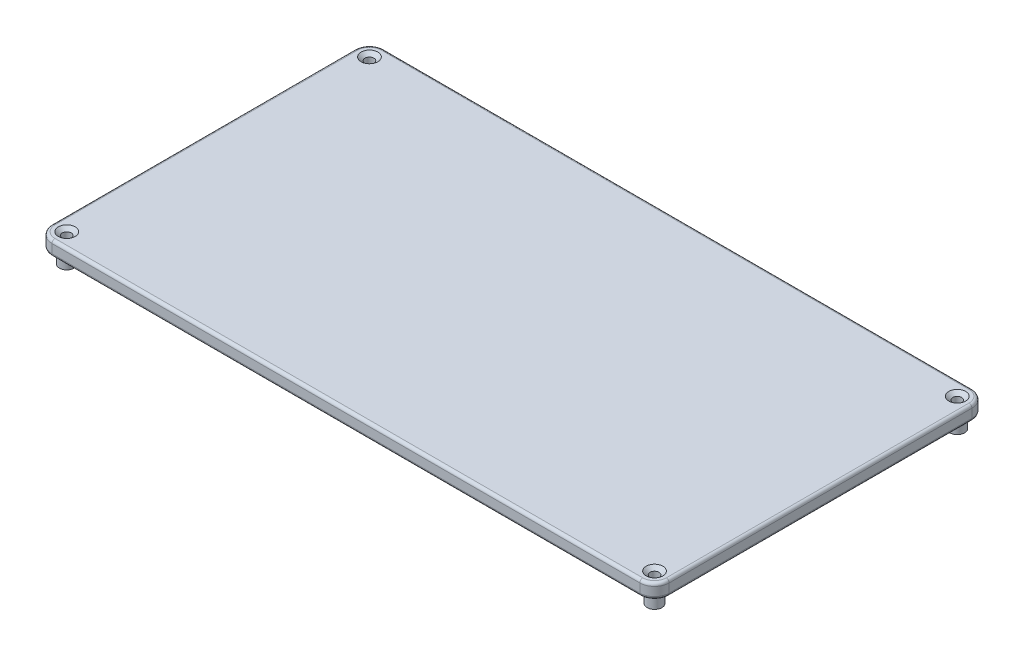
from build123d import *

# Parameters (mm, degrees)
SKETCH1_W                                         = 210
SKETCH1_H                                         = 113
BOSS_EXTRUDE1_DEPTH                               = 5
FILLET1_R                                         = 5
FILLET2_R                                         = 1
CSK_FOR_4_FLAT_HEAD_MACHINE_SCREW_100_D           = 2.9464
CSK_FOR_4_FLAT_HEAD_MACHINE_SCREW_100_CSINK_D     = 5.715
CSK_FOR_4_FLAT_HEAD_MACHINE_SCREW_100_CSINK_ANGLE = 100
SKETCH8_R                                         = 2.4732
BOSS_EXTRUDE2_DEPTH                               = 4.525
SKETCH10_R                                        = 1.525
CUT_EXTRUDE1_DEPTH                                = 1
CUT_EXTRUDE1_DEPTH_BACK                           = 10.525
SKETCH11_R                                        = 2.525
BOSS_EXTRUDE3_DEPTH                               = 4.525
SKETCH14_R                                        = 1.525
CUT_EXTRUDE2_DEPTH                                = 10.5250001
SKETCH15_R                                        = 2.525
BOSS_EXTRUDE6_DEPTH                               = 4.525
SKETCH16_R                                        = 1.525
CUT_EXTRUDE3_DEPTH                                = 10.5250001
SKETCH17_R                                        = 2.525
BOSS_EXTRUDE7_DEPTH                               = 4.525
SKETCH18_R                                        = 1.525
CUT_EXTRUDE4_DEPTH                                = 10.5250001


with BuildPart() as part:
    # Sketch1 → Boss-Extrude1 (new body)
    with BuildSketch(Plane(origin=(0, 0, 0), x_dir=(1, 0, 0), z_dir=(0, 1, 0))):
        Rectangle(SKETCH1_W, SKETCH1_H)
    extrude(amount=BOSS_EXTRUDE1_DEPTH)

    # Fillet1
    fillet1_edges = [part.edges().sort_by_distance(p)[0] for p in [
        (105, 2.5, 56.5),
        (-105, 2.5, 56.5),
        (-105, 2.5, -56.5),
        (105, 2.5, -56.5),
    ]]
    fillet(fillet1_edges, radius=FILLET1_R)

    # Fillet2
    fillet2_edges = [part.edges().sort_by_distance(p)[0] for p in [
        (-105, 0, 0),
        (-105, 5, 0),
        (105, 0, 0),
        (0, 0, 56.5),
        (0, 0, -56.5),
        (103.535533906, 0, -55.035533906),
        (103.535533906, 0, 55.035533906),
        (-103.535533906, 0, 55.035533906),
        (-103.535533906, 0, -55.035533906),
        (0, 5, -56.5),
        (105, 5, 0),
        (0, 5, 56.5),
        (103.535533906, 5, -55.035533906),
        (103.535533906, 5, 55.035533906),
        (-103.535533906, 5, 55.035533906),
        (-103.535533906, 5, -55.035533906),
    ]]
    fillet(fillet2_edges, radius=FILLET2_R)

    # CSK for #4 Flat Head Machine Screw (100)1 (through all)
    with Locations(Plane(origin=(0, 5, 0), x_dir=(1, 0, 0), z_dir=(0, 1, 0))):
        with Locations((-100, -51.5), (100, 51.5), (100, -51.5), (-100, 51.5)):
            CounterSinkHole(CSK_FOR_4_FLAT_HEAD_MACHINE_SCREW_100_D / 2, CSK_FOR_4_FLAT_HEAD_MACHINE_SCREW_100_CSINK_D / 2, counter_sink_angle=CSK_FOR_4_FLAT_HEAD_MACHINE_SCREW_100_CSINK_ANGLE)

    # Sketch8 → Boss-Extrude2 (add)
    with BuildSketch(Plane.XZ):
        with Locations((-100, 51.5)):
            Circle(SKETCH8_R)
    extrude(amount=BOSS_EXTRUDE2_DEPTH)

    # Sketch10 → Cut-Extrude1 (cut, two sides)
    with BuildSketch(Plane.XZ.offset(4.525)) as cut_extrude1_sk:
        with Locations((-100, 51.5)):
            Circle(SKETCH10_R)
    extrude(amount=CUT_EXTRUDE1_DEPTH, mode=Mode.SUBTRACT)
    extrude(cut_extrude1_sk.sketch, amount=-CUT_EXTRUDE1_DEPTH_BACK, mode=Mode.SUBTRACT)

    # Sketch11 → Boss-Extrude3 (add)
    with BuildSketch(Plane.XZ):
        with Locations((-100, -51.5)):
            Circle(SKETCH11_R)
    extrude(amount=BOSS_EXTRUDE3_DEPTH)

    # Sketch14 → Cut-Extrude2 (cut, through all)
    with BuildSketch(Plane.XZ.offset(4.525)):
        with Locations((-100, -51.5)):
            Circle(SKETCH14_R)
    extrude(amount=-CUT_EXTRUDE2_DEPTH, mode=Mode.SUBTRACT)

    # Sketch15 → Boss-Extrude6 (add)
    with BuildSketch(Plane.XZ):
        with Locations((100, 51.5)):
            Circle(SKETCH15_R)
    extrude(amount=BOSS_EXTRUDE6_DEPTH)

    # Sketch16 → Cut-Extrude3 (cut, through all)
    with BuildSketch(Plane.XZ.offset(4.525)):
        with Locations((100, 51.5)):
            Circle(SKETCH16_R)
    extrude(amount=-CUT_EXTRUDE3_DEPTH, mode=Mode.SUBTRACT)

    # Sketch17 → Boss-Extrude7 (add)
    with BuildSketch(Plane.XZ):
        with Locations((100, -51.5)):
            Circle(SKETCH17_R)
    extrude(amount=BOSS_EXTRUDE7_DEPTH)

    # Sketch18 → Cut-Extrude4 (cut, through all)
    with BuildSketch(Plane.XZ.offset(4.525)):
        with Locations((100, -51.5)):
            Circle(SKETCH18_R)
    extrude(amount=-CUT_EXTRUDE4_DEPTH, mode=Mode.SUBTRACT)


solid = part.part
